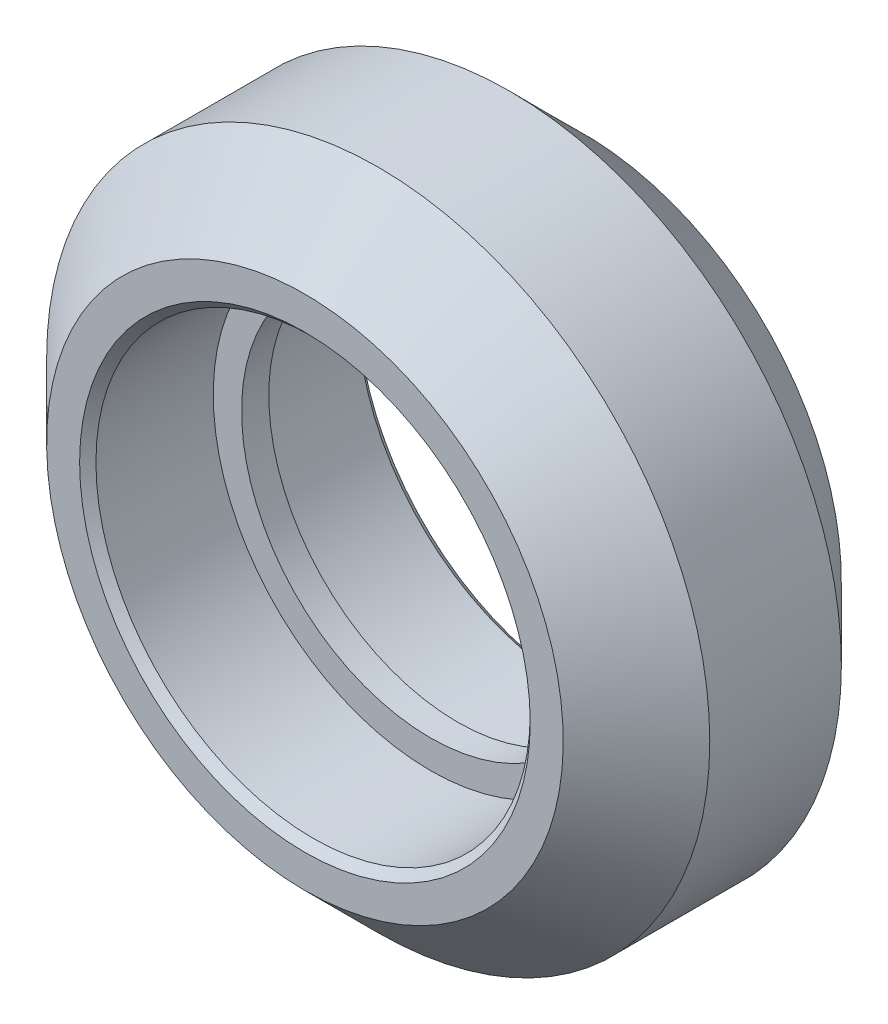
from build123d import *

# Parameters (mm, degrees)
CHAMFER1_SIZE = 0.3


with BuildPart() as part:
    # Sketch1 → Revolve1 (revolve)
    with BuildSketch(Plane(origin=(0, 0, 0), x_dir=(0, 0, -1), z_dir=(1, 0, 0))):
        Polygon((-2.42, 12.195), (2.42, 12.195), (5.115, 9.5), (5.115, 7.987), (0.5, 7.987), (0.5, 6.945), (-0.5, 6.945), (-0.5, 7.987), (-5.115, 7.987), (-5.115, 9.5), align=None)
    revolve(axis=Axis((0, 0, 5.115), (0, 0, -1)))

    # Chamfer1
    chamfer1_edges = [part.edges().sort_by_distance(p)[0] for p in [
        (0, -7.987, 5.115),
        (0, -7.987, -5.115),
    ]]
    chamfer(chamfer1_edges, length=CHAMFER1_SIZE)


solid = part.part
